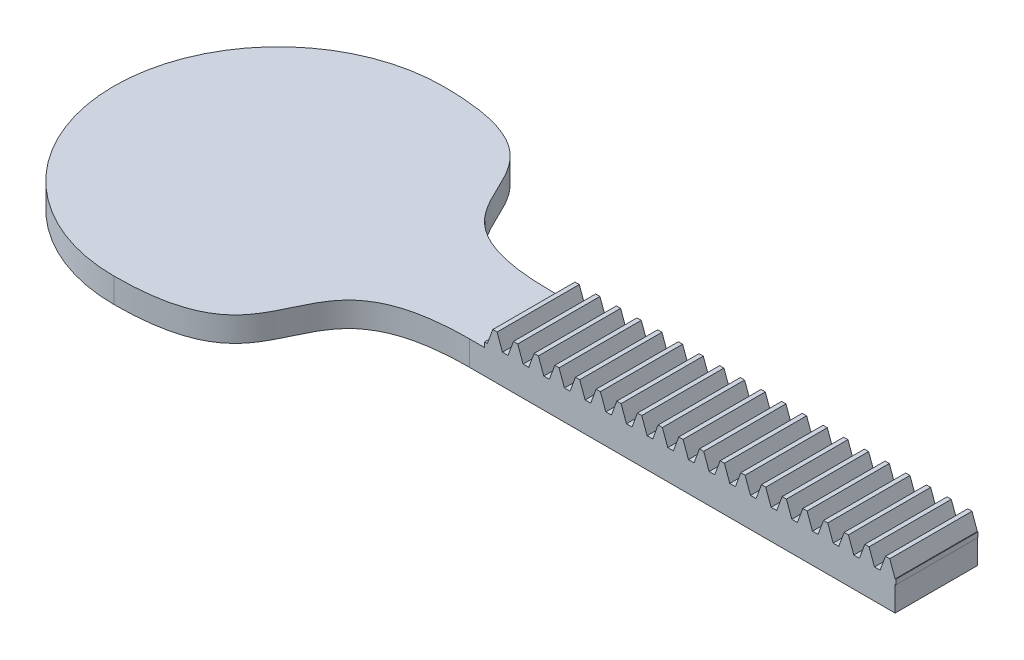
from build123d import *

# Parameters (mm, degrees)
BLANKSKE_W          = 500
BLANKSKE_H          = 24
BLANK_DEPTH         = 100
TOOTHCUTSIM_DEPTH   = 511.466453354
TEETHCUTS_COUNT     = 21
TEETHCUTS_PITCH     = 25.1327412
SKETCH1_W           = 800
SKETCH1_H           = 100
BOSS_EXTRUDE1_DEPTH = 30
SCALE1_SCALE        = 0.25
BOSS_EXTRUDE2_DEPTH = 7.5


with BuildPart() as part:
    # BlankSke → Blank (new body)
    with BuildSketch(Plane.XY):
        with Locations((250, 12)):
            Rectangle(BLANKSKE_W, BLANKSKE_H)
    extrude(amount=-BLANK_DEPTH)

    # TooCutSkeSim → ToothCutSim (cut, through all)
    with BuildSketch(Plane.XY):
        Polygon((3.408482957, 6), (-3.408482957, 6), (-9.969192018, 24.0254), (9.969192018, 24.0254), align=None)
    toothcutsim = extrude(amount=-TOOTHCUTSIM_DEPTH, mode=Mode.SUBTRACT)

    # TeethCuts: ToothCutSim ×21
    with Locations(*[(i * TEETHCUTS_PITCH, 0, 0) for i in range(1, TEETHCUTS_COUNT)]):
        add(toothcutsim, mode=Mode.SUBTRACT)

    # Sketch1 → Boss-Extrude1 (add)
    with BuildSketch(Plane.XZ):
        with Locations((99.246341043, -50)):
            Rectangle(SKETCH1_W, SKETCH1_H)
    extrude(amount=BOSS_EXTRUDE1_DEPTH)


with BuildPart() as part_1:
    # Scale1: scaled about (134.34613588, -9.4300262, -50)
    add(part.part.scale(SCALE1_SCALE).moved(Location((100.75960191, -7.07251965, -37.5))))

    # Sketch3 → Boss-Extrude2 (add)
    with BuildSketch(Plane(origin=(0, -7.07251965, 0), x_dir=(1, 0, 0), z_dir=(0, 1, 0))):
        with BuildLine():
            Line((96.237657296, 62.5), (25.57118717, 62.5))
            Line((25.57118717, 62.5), (25.57118717, 37.5))
            Line((25.57118717, 37.5), (96.237657296, 37.5))
            add(Edge.make_bspline(
                [(25.57118717, 0), (78.47502041, 0), (43.333824056, 37.5), (96.237657296, 37.5)],
                knots=[0, 0, 0, 0, 1, 1, 1, 1], degree=3))
            ThreePointArc((25.57118717, 0), (-24.42881283, 50), (25.57118717, 100))
            add(Edge.make_bspline(
                [(25.57118717, 100), (78.47502041, 100), (43.333824056, 62.5), (96.237657296, 62.5)],
                knots=[0, 0, 0, 0, 1, 1, 1, 1], degree=3))
        make_face()
    extrude(amount=-BOSS_EXTRUDE2_DEPTH)


solid = part_1.part
